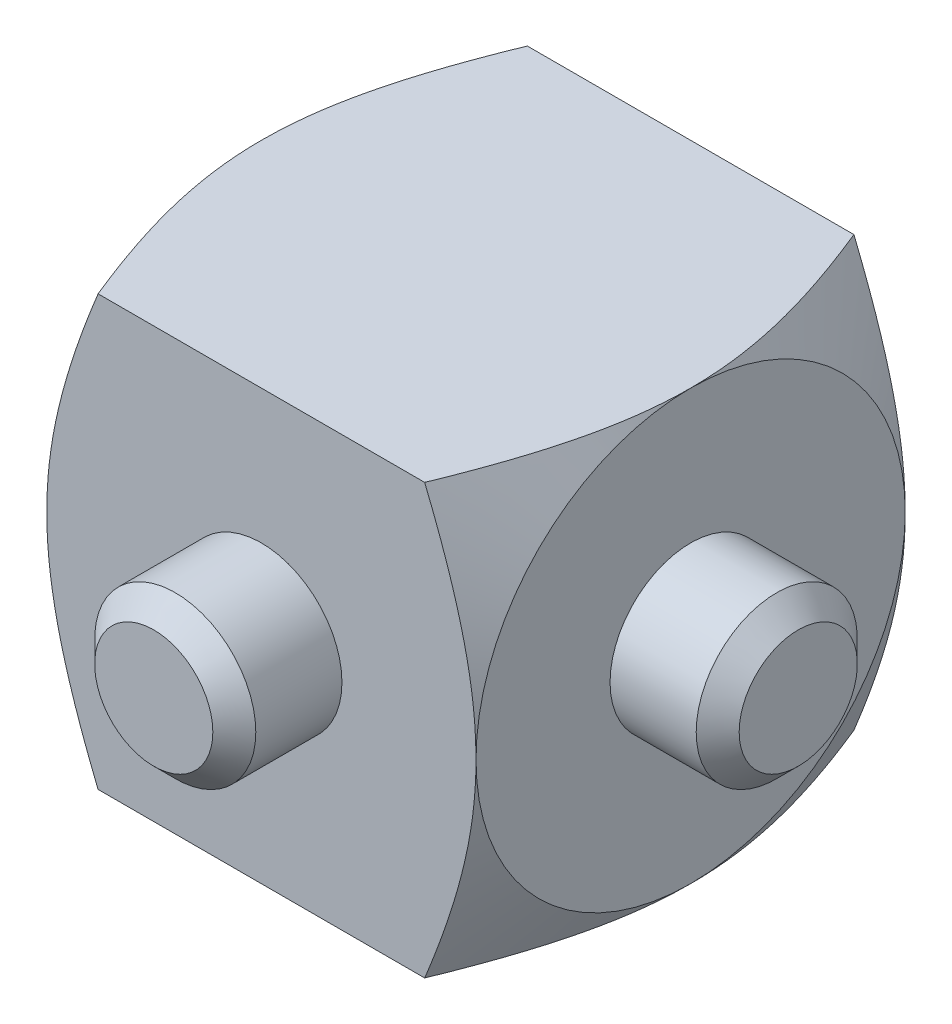
from build123d import *

# Parameters (mm, degrees)
SKETCH1_W               = 25.3746
SKETCH1_H               = 25.3746
BOSS_EXTRUDE1_DEPTH     = 12.6873
SKETCH2_OUTSIDE_W       = 147.284
SKETCH2_OUTSIDE_H       = 147.284
SKETCH2_OUTSIDE_R       = 12.6873
CUT_EXTRUDE1_DEPTH      = 32.077411214
CUT_EXTRUDE1_DRAFT      = -60
MIRROR1_COPY_1_SKETCH_W = 147.284
MIRROR1_COPY_1_SKETCH_H = 147.284
MIRROR1_COPY_1_SKETCH_R = 12.6873
MIRROR1_COPY_1_DEPTH    = 32.077411214
MIRROR1_COPY_1_DRAFT    = -60
CUT_EXTRUDE2_DEPTH      = 22.975048211
CUT_EXTRUDE2_DEPTH_BACK = 22.975048211
SKETCH3_R               = 4.7625
SKETCH3_2_R             = 4.7625
BOSS_EXTRUDE3_DEPTH     = 19.05
CHAMFER6_SIZE           = 1.27


with BuildPart() as part:
    # Sketch1 → Boss-Extrude1 (new, symmetric)
    with BuildSketch(Plane.XY):
        Rectangle(SKETCH1_W, SKETCH1_H)
    extrude(amount=BOSS_EXTRUDE1_DEPTH, both=True)


with BuildPart() as cut_extrude1_tool:
    # Sketch2 outside → Cut-Extrude1 (with draft: the straight prism first)
    with BuildSketch(Plane(origin=(12.6873, 0, 0), x_dir=(0, 0, -1), z_dir=(1, 0, 0))):
        Rectangle(SKETCH2_OUTSIDE_W, SKETCH2_OUTSIDE_H)
        Circle(SKETCH2_OUTSIDE_R, mode=Mode.SUBTRACT)
    extrude(amount=-CUT_EXTRUDE1_DEPTH)
    # Cut-Extrude1: the draft: its side faces are tilted about the plane it starts from
    cut_extrude1_sides = [cut_extrude1_tool.faces().sort_by_distance(p)[0] for p in [
        (-3.351405607, -73.642, 0),
        (-3.351405607, 0, -73.642),
        (-3.351405607, 73.642, 0),
        (-3.351405607, 0, 73.642),
        (-3.351405607, 0, 12.6873),
    ]]
    draft(cut_extrude1_sides, Plane(origin=(12.6873, 0, 0), x_dir=(0, 0, -1), z_dir=(1, 0, 0)), CUT_EXTRUDE1_DRAFT)


with BuildPart() as part_1:
    add(part.part)

    # Cut-Extrude1: cut by cut_extrude1_tool
    add(cut_extrude1_tool.part, mode=Mode.SUBTRACT)


with BuildPart() as mirror1_copy_1_tool:
    # Mirror1 copy 1 sketch → Mirror1 copy 1 (with draft: the straight prism first)
    with BuildSketch(Plane(origin=(-12.6873, 0, 0), x_dir=(0, 0, -1), z_dir=(-1, 0, 0))):
        Rectangle(MIRROR1_COPY_1_SKETCH_W, MIRROR1_COPY_1_SKETCH_H)
        Circle(MIRROR1_COPY_1_SKETCH_R, mode=Mode.SUBTRACT)
    extrude(amount=-MIRROR1_COPY_1_DEPTH)
    # Mirror1 copy 1: the draft: its side faces are tilted about the plane it starts from
    mirror1_copy_1_sides = [mirror1_copy_1_tool.faces().sort_by_distance(p)[0] for p in [
        (3.351405607, -73.642, 0),
        (3.351405607, 0, -73.642),
        (3.351405607, 73.642, 0),
        (3.351405607, 0, 73.642),
        (3.351405607, 0, 12.6873),
    ]]
    draft(mirror1_copy_1_sides, Plane(origin=(-12.6873, 0, 0), x_dir=(0, 0, -1), z_dir=(-1, 0, 0)), MIRROR1_COPY_1_DRAFT)


with BuildPart() as part_2:
    add(part_1.part)

    # Mirror1 copy 1: cut by mirror1_copy_1_tool
    add(mirror1_copy_1_tool.part, mode=Mode.SUBTRACT)

    # Sketch3 → Cut-Extrude2 (cut, two sides: drawn at the far end of the back side and taken through both)
    with BuildSketch(Plane.XY.offset(-CUT_EXTRUDE2_DEPTH_BACK)):
        Circle(SKETCH3_R)
    extrude(amount=CUT_EXTRUDE2_DEPTH + CUT_EXTRUDE2_DEPTH_BACK, mode=Mode.SUBTRACT)

    # Sketch3_2 → Boss-Extrude3 (add, symmetric)
    with BuildSketch(Plane.XY):
        Circle(SKETCH3_2_R)
    boss_extrude3 = extrude(amount=BOSS_EXTRUDE3_DEPTH, both=True)

    # Mirror2: Boss-Extrude3 across plane
    add(boss_extrude3.mirror(Plane(origin=(0, 0, 0), x_dir=(-0.7071067811865478, 0, 0.7071067811865472), z_dir=(-0.7071067811865475, 0, -0.7071067811865477))))

    # Chamfer6
    chamfer6_edges = [part_2.edges().sort_by_distance(p)[0] for p in [
        (-4.7625, 0, -19.05),
        (-19.05, 0, 4.7625),
        (19.05, 0, 4.7625),
        (-4.7625, 0, 19.05),
    ]]
    chamfer(chamfer6_edges, length=CHAMFER6_SIZE)


solid = part_2.part
